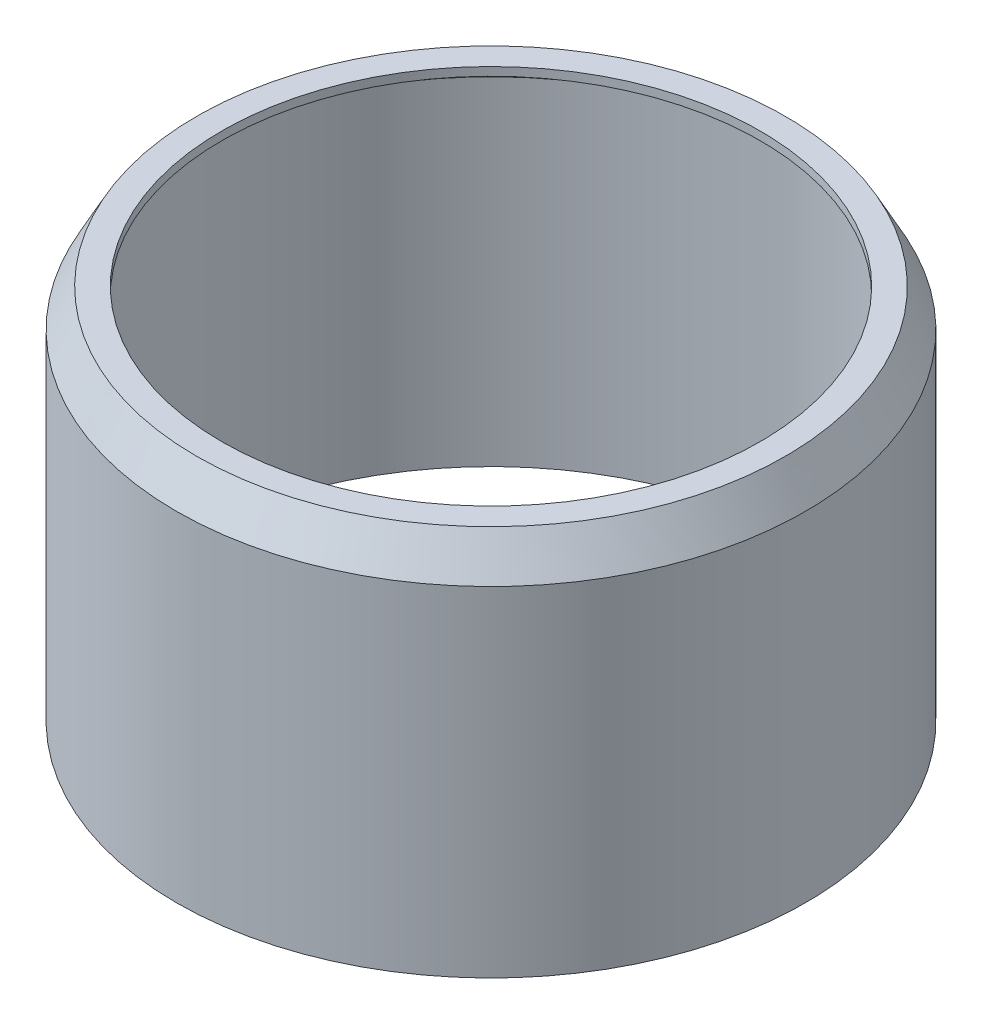
from build123d import *

# Parameters (mm, degrees)
SKETCH_1_R      = 35
SKETCH_1_R_2    = 32
EXTRUDE_1_DEPTH = 1


with BuildPart() as part:
    # 草图1 → 凸台-拉伸1 (new body)
    with BuildSketch(Plane(origin=(0, 0, 0), x_dir=(1, 0, 0), z_dir=(0, 1, 0))):
        Circle(SKETCH_1_R)
        Circle(SKETCH_1_R_2, mode=Mode.SUBTRACT)
    extrude(amount=EXTRUDE_1_DEPTH)

    # 草图2 → 旋转1 (revolve)
    with BuildSketch(Plane.XY):
        Polygon((35, 1), (37.395208955, -3.470302207), (37.395208955, -43.771735553), (37.072710077, -43.771735553), (37.072710077, -3.643098623), (35, 0.549668864), align=None)
    revolve(axis=Axis((0, 0, 0), (0, -1, 0)))


solid = part.part
